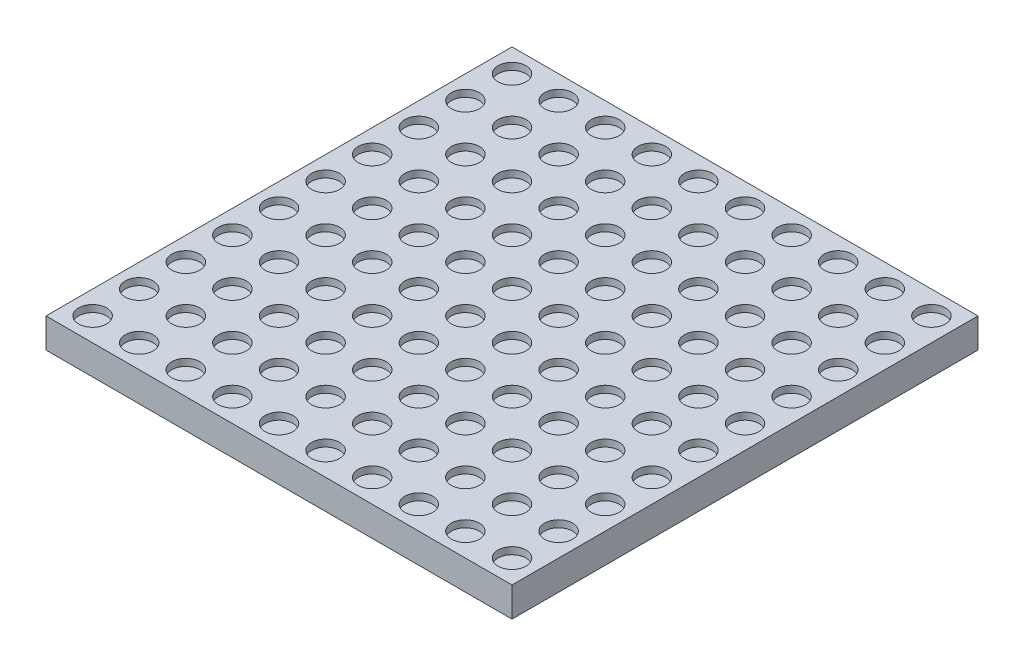
from build123d import *

# Parameters (mm, degrees)
SKETCH1_W           = 100
SKETCH1_H           = 100
BOSS_EXTRUDE1_DEPTH = 6.35
SKETCH2_R           = 3
CUT_EXTRUDE1_DEPTH  = 1.5


with BuildPart() as part:
    # Sketch1 → Boss-Extrude1 (new body)
    with BuildSketch(Plane(origin=(0, 0, 0), x_dir=(1, 0, 0), z_dir=(0, 1, 0))):
        with Locations((50, 50)):
            Rectangle(SKETCH1_W, SKETCH1_H)
    extrude(amount=BOSS_EXTRUDE1_DEPTH)

    # Sketch2 → Cut-Extrude1 (cut)
    with BuildSketch(Plane(origin=(0, 6.35, 0), x_dir=(1, 0, 0), z_dir=(0, 1, 0))):
        with Locations((5, 95)):
            Circle(SKETCH2_R)
        with Locations((15, 95)):
            Circle(SKETCH2_R)
        with Locations((25, 95)):
            Circle(SKETCH2_R)
        with Locations((35, 95)):
            Circle(SKETCH2_R)
        with Locations((45, 95)):
            Circle(SKETCH2_R)
        with Locations((55, 95)):
            Circle(SKETCH2_R)
        with Locations((65, 95)):
            Circle(SKETCH2_R)
        with Locations((75, 95)):
            Circle(SKETCH2_R)
        with Locations((85, 95)):
            Circle(SKETCH2_R)
        with Locations((95, 95)):
            Circle(SKETCH2_R)
        with Locations((15, 85)):
            Circle(SKETCH2_R)
        with Locations((25, 85)):
            Circle(SKETCH2_R)
        with Locations((35, 85)):
            Circle(SKETCH2_R)
        with Locations((45, 85)):
            Circle(SKETCH2_R)
        with Locations((55, 85)):
            Circle(SKETCH2_R)
        with Locations((65, 85)):
            Circle(SKETCH2_R)
        with Locations((75, 85)):
            Circle(SKETCH2_R)
        with Locations((85, 85)):
            Circle(SKETCH2_R)
        with Locations((95, 85)):
            Circle(SKETCH2_R)
        with Locations((15, 75)):
            Circle(SKETCH2_R)
        with Locations((25, 75)):
            Circle(SKETCH2_R)
        with Locations((35, 75)):
            Circle(SKETCH2_R)
        with Locations((45, 75)):
            Circle(SKETCH2_R)
        with Locations((55, 75)):
            Circle(SKETCH2_R)
        with Locations((65, 75)):
            Circle(SKETCH2_R)
        with Locations((75, 75)):
            Circle(SKETCH2_R)
        with Locations((85, 75)):
            Circle(SKETCH2_R)
        with Locations((95, 75)):
            Circle(SKETCH2_R)
        with Locations((15, 65)):
            Circle(SKETCH2_R)
        with Locations((25, 65)):
            Circle(SKETCH2_R)
        with Locations((35, 65)):
            Circle(SKETCH2_R)
        with Locations((45, 65)):
            Circle(SKETCH2_R)
        with Locations((55, 65)):
            Circle(SKETCH2_R)
        with Locations((65, 65)):
            Circle(SKETCH2_R)
        with Locations((75, 65)):
            Circle(SKETCH2_R)
        with Locations((85, 65)):
            Circle(SKETCH2_R)
        with Locations((95, 65)):
            Circle(SKETCH2_R)
        with Locations((15, 55)):
            Circle(SKETCH2_R)
        with Locations((25, 55)):
            Circle(SKETCH2_R)
        with Locations((35, 55)):
            Circle(SKETCH2_R)
        with Locations((45, 55)):
            Circle(SKETCH2_R)
        with Locations((55, 55)):
            Circle(SKETCH2_R)
        with Locations((65, 55)):
            Circle(SKETCH2_R)
        with Locations((75, 55)):
            Circle(SKETCH2_R)
        with Locations((85, 55)):
            Circle(SKETCH2_R)
        with Locations((95, 55)):
            Circle(SKETCH2_R)
        with Locations((15, 45)):
            Circle(SKETCH2_R)
        with Locations((25, 45)):
            Circle(SKETCH2_R)
        with Locations((35, 45)):
            Circle(SKETCH2_R)
        with Locations((45, 45)):
            Circle(SKETCH2_R)
        with Locations((55, 45)):
            Circle(SKETCH2_R)
        with Locations((65, 45)):
            Circle(SKETCH2_R)
        with Locations((75, 45)):
            Circle(SKETCH2_R)
        with Locations((85, 45)):
            Circle(SKETCH2_R)
        with Locations((95, 45)):
            Circle(SKETCH2_R)
        with Locations((15, 35)):
            Circle(SKETCH2_R)
        with Locations((25, 35)):
            Circle(SKETCH2_R)
        with Locations((35, 35)):
            Circle(SKETCH2_R)
        with Locations((45, 35)):
            Circle(SKETCH2_R)
        with Locations((55, 35)):
            Circle(SKETCH2_R)
        with Locations((65, 35)):
            Circle(SKETCH2_R)
        with Locations((75, 35)):
            Circle(SKETCH2_R)
        with Locations((85, 35)):
            Circle(SKETCH2_R)
        with Locations((95, 35)):
            Circle(SKETCH2_R)
        with Locations((15, 25)):
            Circle(SKETCH2_R)
        with Locations((25, 25)):
            Circle(SKETCH2_R)
        with Locations((35, 25)):
            Circle(SKETCH2_R)
        with Locations((45, 25)):
            Circle(SKETCH2_R)
        with Locations((55, 25)):
            Circle(SKETCH2_R)
        with Locations((65, 25)):
            Circle(SKETCH2_R)
        with Locations((75, 25)):
            Circle(SKETCH2_R)
        with Locations((85, 25)):
            Circle(SKETCH2_R)
        with Locations((95, 25)):
            Circle(SKETCH2_R)
        with Locations((15, 15)):
            Circle(SKETCH2_R)
        with Locations((25, 15)):
            Circle(SKETCH2_R)
        with Locations((35, 15)):
            Circle(SKETCH2_R)
        with Locations((45, 15)):
            Circle(SKETCH2_R)
        with Locations((55, 15)):
            Circle(SKETCH2_R)
        with Locations((65, 15)):
            Circle(SKETCH2_R)
        with Locations((75, 15)):
            Circle(SKETCH2_R)
        with Locations((85, 15)):
            Circle(SKETCH2_R)
        with Locations((95, 15)):
            Circle(SKETCH2_R)
        with Locations((15, 5)):
            Circle(SKETCH2_R)
        with Locations((25, 5)):
            Circle(SKETCH2_R)
        with Locations((35, 5)):
            Circle(SKETCH2_R)
        with Locations((45, 5)):
            Circle(SKETCH2_R)
        with Locations((55, 5)):
            Circle(SKETCH2_R)
        with Locations((65, 5)):
            Circle(SKETCH2_R)
        with Locations((75, 5)):
            Circle(SKETCH2_R)
        with Locations((85, 5)):
            Circle(SKETCH2_R)
        with Locations((95, 5)):
            Circle(SKETCH2_R)
        with Locations((5, 85)):
            Circle(SKETCH2_R)
        with Locations((5, 75)):
            Circle(SKETCH2_R)
        with Locations((5, 65)):
            Circle(SKETCH2_R)
        with Locations((5, 55)):
            Circle(SKETCH2_R)
        with Locations((5, 45)):
            Circle(SKETCH2_R)
        with Locations((5, 35)):
            Circle(SKETCH2_R)
        with Locations((5, 25)):
            Circle(SKETCH2_R)
        with Locations((5, 15)):
            Circle(SKETCH2_R)
        with Locations((5, 5)):
            Circle(SKETCH2_R)
    extrude(amount=-CUT_EXTRUDE1_DEPTH, mode=Mode.SUBTRACT)


solid = part.part
